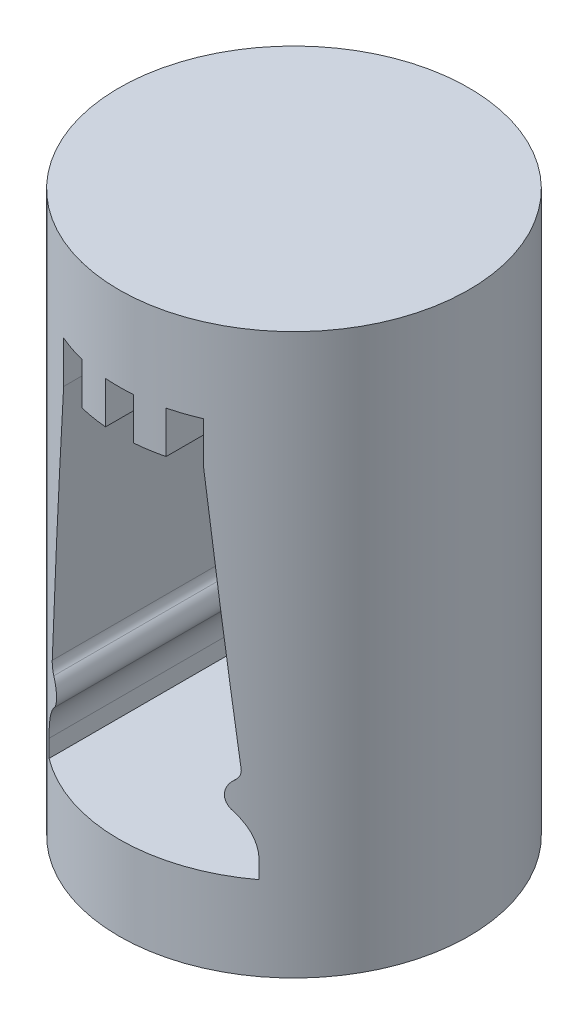
from build123d import *

# Parameters (mm, degrees)
SKETCH2_R               = 12.5
BOSS_EXTRUDE1_DEPTH     = 20
CUT_EXTRUDE1_DEPTH      = 13.5
CUT_EXTRUDE1_DEPTH_BACK = 13.5
SKETCH4_R               = 3
CUT_EXTRUDE2_DEPTH      = 3


with BuildPart() as part:
    # Sketch2 → Boss-Extrude1 (new body, symmetric)
    with BuildSketch(Plane(origin=(0, 0, 0), x_dir=(1, 0, 0), z_dir=(0, 1, 0))):
        Circle(SKETCH2_R)
    extrude(amount=BOSS_EXTRUDE1_DEPTH, both=True)

    # Sketch3 → Cut-Extrude1 (cut, two sides)
    with BuildSketch(Plane.XY) as cut_extrude1_sk:
        with BuildLine():
            Line((-7.5, -14), (7.5, -14))
            Line((7.5, -14), (7.5, -12.75))
            ThreePointArc((7.5, -12.75), (7.203207399, -11.211161096), (6.35540622, -9.893077571))
            ThreePointArc((6.35540622, -9.893077571), (5.999449038, -8.930951878), (6.455951755, -8.012258985))
            ThreePointArc((6.455951755, -8.012258985), (6.691617305, -7.687574573), (6.749863955, -7.290629305))
            Line((6.749863955, -7.290629305), (5, 11))
            Line((5, 11), (5, 14))
            Line((5, 14), (3, 14))
            Line((3, 14), (3, 11))
            Line((3, 11), (1, 11))
            Line((1, 11), (1, 14))
            Line((1, 14), (-1, 14))
            Line((-1, 14), (-1, 11))
            Line((-1, 11), (-3, 11))
            Line((-3, 11), (-3, 14))
            Line((-3, 14), (-5, 14))
            Line((-5, 14), (-5, 11))
            Line((-5, 11), (-6.749863955, -7.290629305))
            ThreePointArc((-6.749863955, -7.290629305), (-6.691617305, -7.687574573), (-6.455951755, -8.012258985))
            ThreePointArc((-6.455951755, -8.012258985), (-5.999449038, -8.930951878), (-6.35540622, -9.893077571))
            ThreePointArc((-6.35540622, -9.893077571), (-7.203207399, -11.211161096), (-7.5, -12.75))
            Line((-7.5, -12.75), (-7.5, -14))
        make_face()
    extrude(amount=CUT_EXTRUDE1_DEPTH, mode=Mode.SUBTRACT)
    extrude(cut_extrude1_sk.sketch, amount=-CUT_EXTRUDE1_DEPTH_BACK, mode=Mode.SUBTRACT)

    # Sketch4 → Cut-Extrude2 (cut)
    with BuildSketch(Plane(origin=(0, -20, 0), x_dir=(-1, 0, 0), z_dir=(0, -1, 0))):
        Circle(SKETCH4_R)
    extrude(amount=-CUT_EXTRUDE2_DEPTH, mode=Mode.SUBTRACT)


solid = part.part
